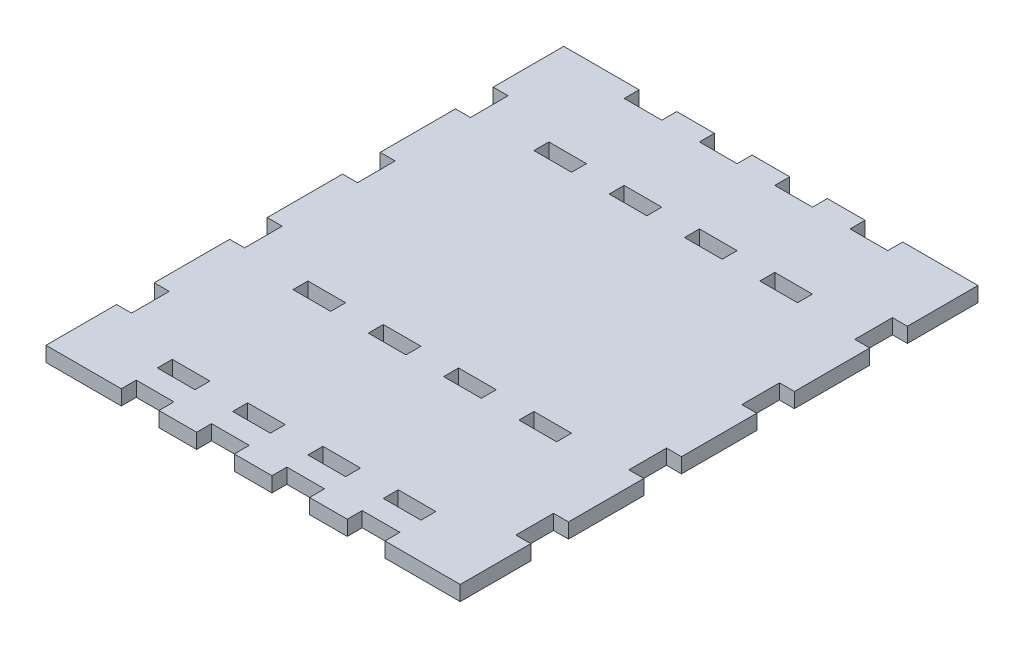
from build123d import *

# Parameters (mm, degrees)
SKETCH1_W           = 88
SKETCH1_H           = 110
BOSS_EXTRUDE1_DEPTH = 3.175
CUT_EXTRUDE1_REACH  = 5.175
SKETCH2_W           = 8
SKETCH2_H           = 3.175
SKETCH2_W_2         = 3.175
SKETCH2_H_2         = 8
CUT_EXTRUDE2_REACH  = 5.175
SKETCH3_W           = 8
SKETCH3_H           = 3.175
CUT_EXTRUDE3_REACH  = 5.175
SKETCH4_W           = 8
SKETCH4_H           = 3.175


with BuildPart() as part:
    # Sketch1 → Boss-Extrude1 (new body)
    with BuildSketch(Plane(origin=(0, 0, 0), x_dir=(1, 0, 0), z_dir=(0, 1, 0))):
        with Locations((44, -55)):
            Rectangle(SKETCH1_W, SKETCH1_H)
    extrude(amount=BOSS_EXTRUDE1_DEPTH)

    # Sketch2 → Cut-Extrude1 (cut, up to next)
    with BuildSketch(Plane(origin=(0, 3.175, 0), x_dir=(1, 0, 0), z_dir=(0, 1, 0)), mode=Mode.PRIVATE) as cut_extrude1_sk1:
        with Locations((68, -1.5875)):
            Rectangle(SKETCH2_W, SKETCH2_H)
    cut_extrude1_tool1 = extrude(cut_extrude1_sk1.sketch, amount=-CUT_EXTRUDE1_REACH, mode=Mode.PRIVATE) & part.part
    add(cut_extrude1_tool1.solids().sort_by_distance((68, 3.175, 1.5875))[0], mode=Mode.SUBTRACT)
    # Sketch2 → Cut-Extrude1 (cut, up to next)
    with BuildSketch(Plane(origin=(0, 3.175, 0), x_dir=(1, 0, 0), z_dir=(0, 1, 0)), mode=Mode.PRIVATE) as cut_extrude1_sk2:
        with Locations((52, -1.5875)):
            Rectangle(SKETCH2_W, SKETCH2_H)
    cut_extrude1_tool2 = extrude(cut_extrude1_sk2.sketch, amount=-CUT_EXTRUDE1_REACH, mode=Mode.PRIVATE) & part.part
    add(cut_extrude1_tool2.solids().sort_by_distance((52, 3.175, 1.5875))[0], mode=Mode.SUBTRACT)
    # Sketch2 → Cut-Extrude1 (cut, up to next)
    with BuildSketch(Plane(origin=(0, 3.175, 0), x_dir=(1, 0, 0), z_dir=(0, 1, 0)), mode=Mode.PRIVATE) as cut_extrude1_sk3:
        with Locations((20, -1.5875)):
            Rectangle(SKETCH2_W, SKETCH2_H)
    cut_extrude1_tool3 = extrude(cut_extrude1_sk3.sketch, amount=-CUT_EXTRUDE1_REACH, mode=Mode.PRIVATE) & part.part
    add(cut_extrude1_tool3.solids().sort_by_distance((20, 3.175, 1.5875))[0], mode=Mode.SUBTRACT)
    # Sketch2 → Cut-Extrude1 (cut, up to next)
    with BuildSketch(Plane(origin=(0, 3.175, 0), x_dir=(1, 0, 0), z_dir=(0, 1, 0)), mode=Mode.PRIVATE) as cut_extrude1_sk4:
        with Locations((36, -1.5875)):
            Rectangle(SKETCH2_W, SKETCH2_H)
    cut_extrude1_tool4 = extrude(cut_extrude1_sk4.sketch, amount=-CUT_EXTRUDE1_REACH, mode=Mode.PRIVATE) & part.part
    add(cut_extrude1_tool4.solids().sort_by_distance((36, 3.175, 1.5875))[0], mode=Mode.SUBTRACT)
    # Sketch2 → Cut-Extrude1 (cut, up to next)
    with BuildSketch(Plane(origin=(0, 3.175, 0), x_dir=(1, 0, 0), z_dir=(0, 1, 0)), mode=Mode.PRIVATE) as cut_extrude1_sk5:
        with Locations((1.5875, -19)):
            Rectangle(SKETCH2_W_2, SKETCH2_H_2)
    cut_extrude1_tool5 = extrude(cut_extrude1_sk5.sketch, amount=-CUT_EXTRUDE1_REACH, mode=Mode.PRIVATE) & part.part
    add(cut_extrude1_tool5.solids().sort_by_distance((1.5875, 3.175, 19))[0], mode=Mode.SUBTRACT)
    # Sketch2 → Cut-Extrude1 (cut, up to next)
    with BuildSketch(Plane(origin=(0, 3.175, 0), x_dir=(1, 0, 0), z_dir=(0, 1, 0)), mode=Mode.PRIVATE) as cut_extrude1_sk6:
        with Locations((1.5875, -43)):
            Rectangle(SKETCH2_W_2, SKETCH2_H_2)
    cut_extrude1_tool6 = extrude(cut_extrude1_sk6.sketch, amount=-CUT_EXTRUDE1_REACH, mode=Mode.PRIVATE) & part.part
    add(cut_extrude1_tool6.solids().sort_by_distance((1.5875, 3.175, 43))[0], mode=Mode.SUBTRACT)
    # Sketch2 → Cut-Extrude1 (cut, up to next)
    with BuildSketch(Plane(origin=(0, 3.175, 0), x_dir=(1, 0, 0), z_dir=(0, 1, 0)), mode=Mode.PRIVATE) as cut_extrude1_sk7:
        with Locations((1.5875, -91)):
            Rectangle(SKETCH2_W_2, SKETCH2_H_2)
    cut_extrude1_tool7 = extrude(cut_extrude1_sk7.sketch, amount=-CUT_EXTRUDE1_REACH, mode=Mode.PRIVATE) & part.part
    add(cut_extrude1_tool7.solids().sort_by_distance((1.5875, 3.175, 91))[0], mode=Mode.SUBTRACT)
    # Sketch2 → Cut-Extrude1 (cut, up to next)
    with BuildSketch(Plane(origin=(0, 3.175, 0), x_dir=(1, 0, 0), z_dir=(0, 1, 0)), mode=Mode.PRIVATE) as cut_extrude1_sk8:
        with Locations((1.5875, -67)):
            Rectangle(SKETCH2_W_2, SKETCH2_H_2)
    cut_extrude1_tool8 = extrude(cut_extrude1_sk8.sketch, amount=-CUT_EXTRUDE1_REACH, mode=Mode.PRIVATE) & part.part
    add(cut_extrude1_tool8.solids().sort_by_distance((1.5875, 3.175, 67))[0], mode=Mode.SUBTRACT)
    # Sketch2 → Cut-Extrude1 (cut, up to next)
    with BuildSketch(Plane(origin=(0, 3.175, 0), x_dir=(1, 0, 0), z_dir=(0, 1, 0)), mode=Mode.PRIVATE) as cut_extrude1_sk9:
        with Locations((20, -108.4125)):
            Rectangle(SKETCH2_W, SKETCH2_H)
    cut_extrude1_tool9 = extrude(cut_extrude1_sk9.sketch, amount=-CUT_EXTRUDE1_REACH, mode=Mode.PRIVATE) & part.part
    add(cut_extrude1_tool9.solids().sort_by_distance((20, 3.175, 108.4125))[0], mode=Mode.SUBTRACT)
    # Sketch2 → Cut-Extrude1 (cut, up to next)
    with BuildSketch(Plane(origin=(0, 3.175, 0), x_dir=(1, 0, 0), z_dir=(0, 1, 0)), mode=Mode.PRIVATE) as cut_extrude1_sk10:
        with Locations((36, -108.4125)):
            Rectangle(SKETCH2_W, SKETCH2_H)
    cut_extrude1_tool10 = extrude(cut_extrude1_sk10.sketch, amount=-CUT_EXTRUDE1_REACH, mode=Mode.PRIVATE) & part.part
    add(cut_extrude1_tool10.solids().sort_by_distance((36, 3.175, 108.4125))[0], mode=Mode.SUBTRACT)
    # Sketch2 → Cut-Extrude1 (cut, up to next)
    with BuildSketch(Plane(origin=(0, 3.175, 0), x_dir=(1, 0, 0), z_dir=(0, 1, 0)), mode=Mode.PRIVATE) as cut_extrude1_sk11:
        with Locations((68, -108.4125)):
            Rectangle(SKETCH2_W, SKETCH2_H)
    cut_extrude1_tool11 = extrude(cut_extrude1_sk11.sketch, amount=-CUT_EXTRUDE1_REACH, mode=Mode.PRIVATE) & part.part
    add(cut_extrude1_tool11.solids().sort_by_distance((68, 3.175, 108.4125))[0], mode=Mode.SUBTRACT)
    # Sketch2 → Cut-Extrude1 (cut, up to next)
    with BuildSketch(Plane(origin=(0, 3.175, 0), x_dir=(1, 0, 0), z_dir=(0, 1, 0)), mode=Mode.PRIVATE) as cut_extrude1_sk12:
        with Locations((52, -108.4125)):
            Rectangle(SKETCH2_W, SKETCH2_H)
    cut_extrude1_tool12 = extrude(cut_extrude1_sk12.sketch, amount=-CUT_EXTRUDE1_REACH, mode=Mode.PRIVATE) & part.part
    add(cut_extrude1_tool12.solids().sort_by_distance((52, 3.175, 108.4125))[0], mode=Mode.SUBTRACT)
    # Sketch2 → Cut-Extrude1 (cut, up to next)
    with BuildSketch(Plane(origin=(0, 3.175, 0), x_dir=(1, 0, 0), z_dir=(0, 1, 0)), mode=Mode.PRIVATE) as cut_extrude1_sk13:
        with Locations((86.4125, -91)):
            Rectangle(SKETCH2_W_2, SKETCH2_H_2)
    cut_extrude1_tool13 = extrude(cut_extrude1_sk13.sketch, amount=-CUT_EXTRUDE1_REACH, mode=Mode.PRIVATE) & part.part
    add(cut_extrude1_tool13.solids().sort_by_distance((86.4125, 3.175, 91))[0], mode=Mode.SUBTRACT)
    # Sketch2 → Cut-Extrude1 (cut, up to next)
    with BuildSketch(Plane(origin=(0, 3.175, 0), x_dir=(1, 0, 0), z_dir=(0, 1, 0)), mode=Mode.PRIVATE) as cut_extrude1_sk14:
        with Locations((86.4125, -67)):
            Rectangle(SKETCH2_W_2, SKETCH2_H_2)
    cut_extrude1_tool14 = extrude(cut_extrude1_sk14.sketch, amount=-CUT_EXTRUDE1_REACH, mode=Mode.PRIVATE) & part.part
    add(cut_extrude1_tool14.solids().sort_by_distance((86.4125, 3.175, 67))[0], mode=Mode.SUBTRACT)
    # Sketch2 → Cut-Extrude1 (cut, up to next)
    with BuildSketch(Plane(origin=(0, 3.175, 0), x_dir=(1, 0, 0), z_dir=(0, 1, 0)), mode=Mode.PRIVATE) as cut_extrude1_sk15:
        with Locations((86.4125, -19)):
            Rectangle(SKETCH2_W_2, SKETCH2_H_2)
    cut_extrude1_tool15 = extrude(cut_extrude1_sk15.sketch, amount=-CUT_EXTRUDE1_REACH, mode=Mode.PRIVATE) & part.part
    add(cut_extrude1_tool15.solids().sort_by_distance((86.4125, 3.175, 19))[0], mode=Mode.SUBTRACT)
    # Sketch2 → Cut-Extrude1 (cut, up to next)
    with BuildSketch(Plane(origin=(0, 3.175, 0), x_dir=(1, 0, 0), z_dir=(0, 1, 0)), mode=Mode.PRIVATE) as cut_extrude1_sk16:
        with Locations((86.4125, -43)):
            Rectangle(SKETCH2_W_2, SKETCH2_H_2)
    cut_extrude1_tool16 = extrude(cut_extrude1_sk16.sketch, amount=-CUT_EXTRUDE1_REACH, mode=Mode.PRIVATE) & part.part
    add(cut_extrude1_tool16.solids().sort_by_distance((86.4125, 3.175, 43))[0], mode=Mode.SUBTRACT)

    # Sketch3 → Cut-Extrude2 (cut, up to next)
    with BuildSketch(Plane(origin=(0, 3.175, 0), x_dir=(1, 0, 0), z_dir=(0, 1, 0)), mode=Mode.PRIVATE) as cut_extrude2_sk1:
        with Locations((68, -20.7625)):
            Rectangle(SKETCH3_W, SKETCH3_H)
    cut_extrude2_tool1 = extrude(cut_extrude2_sk1.sketch, amount=-CUT_EXTRUDE2_REACH, mode=Mode.PRIVATE) & part.part
    add(cut_extrude2_tool1.solids().sort_by_distance((68, 3.175, 20.7625))[0], mode=Mode.SUBTRACT)
    # Sketch3 → Cut-Extrude2 (cut, up to next)
    with BuildSketch(Plane(origin=(0, 3.175, 0), x_dir=(1, 0, 0), z_dir=(0, 1, 0)), mode=Mode.PRIVATE) as cut_extrude2_sk2:
        with Locations((52, -20.7625)):
            Rectangle(SKETCH3_W, SKETCH3_H)
    cut_extrude2_tool2 = extrude(cut_extrude2_sk2.sketch, amount=-CUT_EXTRUDE2_REACH, mode=Mode.PRIVATE) & part.part
    add(cut_extrude2_tool2.solids().sort_by_distance((52, 3.175, 20.7625))[0], mode=Mode.SUBTRACT)
    # Sketch3 → Cut-Extrude2 (cut, up to next)
    with BuildSketch(Plane(origin=(0, 3.175, 0), x_dir=(1, 0, 0), z_dir=(0, 1, 0)), mode=Mode.PRIVATE) as cut_extrude2_sk3:
        with Locations((20, -20.7625)):
            Rectangle(SKETCH3_W, SKETCH3_H)
    cut_extrude2_tool3 = extrude(cut_extrude2_sk3.sketch, amount=-CUT_EXTRUDE2_REACH, mode=Mode.PRIVATE) & part.part
    add(cut_extrude2_tool3.solids().sort_by_distance((20, 3.175, 20.7625))[0], mode=Mode.SUBTRACT)
    # Sketch3 → Cut-Extrude2 (cut, up to next)
    with BuildSketch(Plane(origin=(0, 3.175, 0), x_dir=(1, 0, 0), z_dir=(0, 1, 0)), mode=Mode.PRIVATE) as cut_extrude2_sk4:
        with Locations((36, -20.7625)):
            Rectangle(SKETCH3_W, SKETCH3_H)
    cut_extrude2_tool4 = extrude(cut_extrude2_sk4.sketch, amount=-CUT_EXTRUDE2_REACH, mode=Mode.PRIVATE) & part.part
    add(cut_extrude2_tool4.solids().sort_by_distance((36, 3.175, 20.7625))[0], mode=Mode.SUBTRACT)

    # Sketch4 → Cut-Extrude3 (cut, up to next)
    with BuildSketch(Plane(origin=(0, 3.175, 0), x_dir=(1, 0, 0), z_dir=(0, 1, 0)), mode=Mode.PRIVATE) as cut_extrude3_sk1:
        with Locations((68, -71.9375)):
            Rectangle(SKETCH4_W, SKETCH4_H)
    cut_extrude3_tool1 = extrude(cut_extrude3_sk1.sketch, amount=-CUT_EXTRUDE3_REACH, mode=Mode.PRIVATE) & part.part
    add(cut_extrude3_tool1.solids().sort_by_distance((68, 3.175, 71.9375))[0], mode=Mode.SUBTRACT)
    # Sketch4 → Cut-Extrude3 (cut, up to next)
    with BuildSketch(Plane(origin=(0, 3.175, 0), x_dir=(1, 0, 0), z_dir=(0, 1, 0)), mode=Mode.PRIVATE) as cut_extrude3_sk2:
        with Locations((52, -71.9375)):
            Rectangle(SKETCH4_W, SKETCH4_H)
    cut_extrude3_tool2 = extrude(cut_extrude3_sk2.sketch, amount=-CUT_EXTRUDE3_REACH, mode=Mode.PRIVATE) & part.part
    add(cut_extrude3_tool2.solids().sort_by_distance((52, 3.175, 71.9375))[0], mode=Mode.SUBTRACT)
    # Sketch4 → Cut-Extrude3 (cut, up to next)
    with BuildSketch(Plane(origin=(0, 3.175, 0), x_dir=(1, 0, 0), z_dir=(0, 1, 0)), mode=Mode.PRIVATE) as cut_extrude3_sk3:
        with Locations((20, -71.9375)):
            Rectangle(SKETCH4_W, SKETCH4_H)
    cut_extrude3_tool3 = extrude(cut_extrude3_sk3.sketch, amount=-CUT_EXTRUDE3_REACH, mode=Mode.PRIVATE) & part.part
    add(cut_extrude3_tool3.solids().sort_by_distance((20, 3.175, 71.9375))[0], mode=Mode.SUBTRACT)
    # Sketch4 → Cut-Extrude3 (cut, up to next)
    with BuildSketch(Plane(origin=(0, 3.175, 0), x_dir=(1, 0, 0), z_dir=(0, 1, 0)), mode=Mode.PRIVATE) as cut_extrude3_sk4:
        with Locations((36, -71.9375)):
            Rectangle(SKETCH4_W, SKETCH4_H)
    cut_extrude3_tool4 = extrude(cut_extrude3_sk4.sketch, amount=-CUT_EXTRUDE3_REACH, mode=Mode.PRIVATE) & part.part
    add(cut_extrude3_tool4.solids().sort_by_distance((36, 3.175, 71.9375))[0], mode=Mode.SUBTRACT)
    # Sketch4 → Cut-Extrude3 (cut, up to next)
    with BuildSketch(Plane(origin=(0, 3.175, 0), x_dir=(1, 0, 0), z_dir=(0, 1, 0)), mode=Mode.PRIVATE) as cut_extrude3_sk5:
        with Locations((68, -100.7625)):
            Rectangle(SKETCH4_W, SKETCH4_H)
    cut_extrude3_tool5 = extrude(cut_extrude3_sk5.sketch, amount=-CUT_EXTRUDE3_REACH, mode=Mode.PRIVATE) & part.part
    add(cut_extrude3_tool5.solids().sort_by_distance((68, 3.175, 100.7625))[0], mode=Mode.SUBTRACT)
    # Sketch4 → Cut-Extrude3 (cut, up to next)
    with BuildSketch(Plane(origin=(0, 3.175, 0), x_dir=(1, 0, 0), z_dir=(0, 1, 0)), mode=Mode.PRIVATE) as cut_extrude3_sk6:
        with Locations((52, -100.7625)):
            Rectangle(SKETCH4_W, SKETCH4_H)
    cut_extrude3_tool6 = extrude(cut_extrude3_sk6.sketch, amount=-CUT_EXTRUDE3_REACH, mode=Mode.PRIVATE) & part.part
    add(cut_extrude3_tool6.solids().sort_by_distance((52, 3.175, 100.7625))[0], mode=Mode.SUBTRACT)
    # Sketch4 → Cut-Extrude3 (cut, up to next)
    with BuildSketch(Plane(origin=(0, 3.175, 0), x_dir=(1, 0, 0), z_dir=(0, 1, 0)), mode=Mode.PRIVATE) as cut_extrude3_sk7:
        with Locations((20, -100.7625)):
            Rectangle(SKETCH4_W, SKETCH4_H)
    cut_extrude3_tool7 = extrude(cut_extrude3_sk7.sketch, amount=-CUT_EXTRUDE3_REACH, mode=Mode.PRIVATE) & part.part
    add(cut_extrude3_tool7.solids().sort_by_distance((20, 3.175, 100.7625))[0], mode=Mode.SUBTRACT)
    # Sketch4 → Cut-Extrude3 (cut, up to next)
    with BuildSketch(Plane(origin=(0, 3.175, 0), x_dir=(1, 0, 0), z_dir=(0, 1, 0)), mode=Mode.PRIVATE) as cut_extrude3_sk8:
        with Locations((36, -100.7625)):
            Rectangle(SKETCH4_W, SKETCH4_H)
    cut_extrude3_tool8 = extrude(cut_extrude3_sk8.sketch, amount=-CUT_EXTRUDE3_REACH, mode=Mode.PRIVATE) & part.part
    add(cut_extrude3_tool8.solids().sort_by_distance((36, 3.175, 100.7625))[0], mode=Mode.SUBTRACT)


solid = part.part
